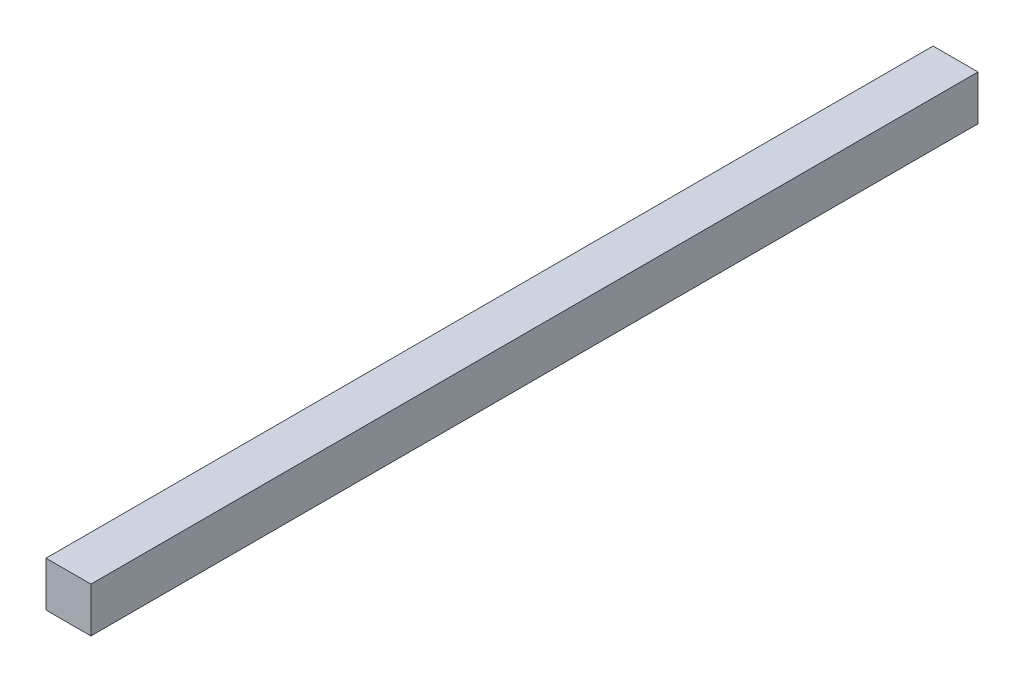
from build123d import *

# Parameters (mm, degrees)
SZKIC1_W                    = 20
SZKIC1_H                    = 20
DODANIE_WYCI_GNI_CIE1_DEPTH = 395


with BuildPart() as part:
    # Szkic1 → Dodanie-wyciągnięcie1 (new body)
    with BuildSketch(Plane.XY):
        with Locations((10, 10)):
            Rectangle(SZKIC1_W, SZKIC1_H)
    extrude(amount=-DODANIE_WYCI_GNI_CIE1_DEPTH)


solid = part.part
